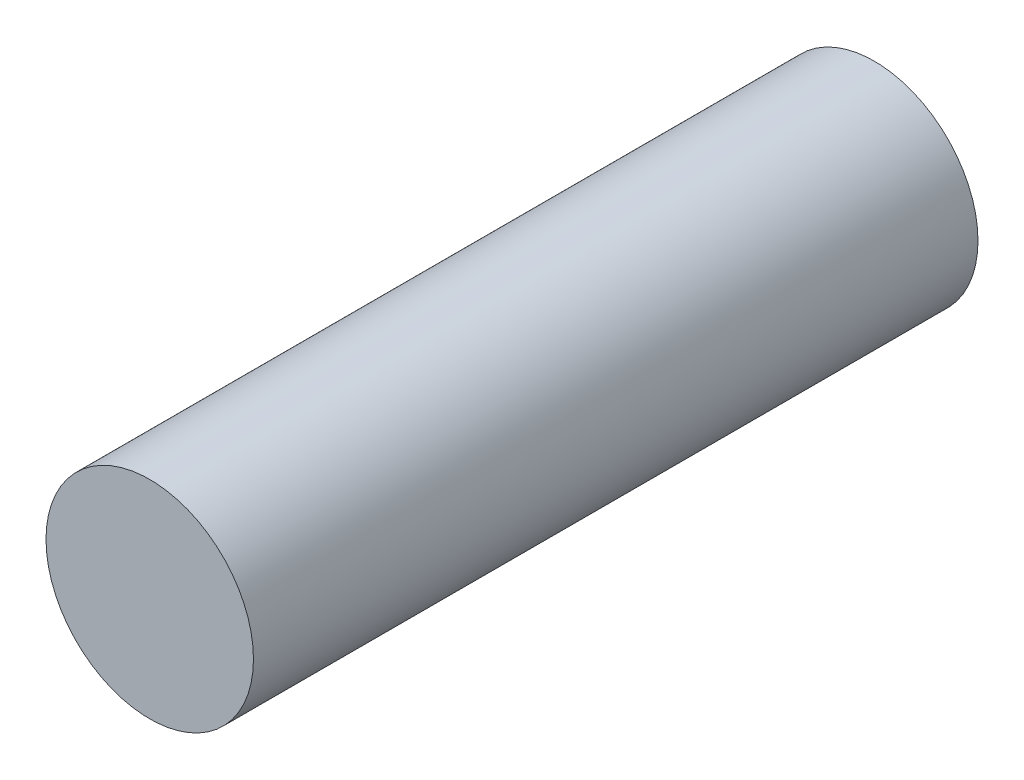
from build123d import *

# Parameters (mm, degrees)
SKETCH1_R           = 16.75
BOSS_EXTRUDE1_DEPTH = 117


with BuildPart() as part:
    # Sketch1 → Boss-Extrude1 (new body)
    with BuildSketch(Plane.XY):
        Circle(SKETCH1_R)
    extrude(amount=BOSS_EXTRUDE1_DEPTH)


solid = part.part
